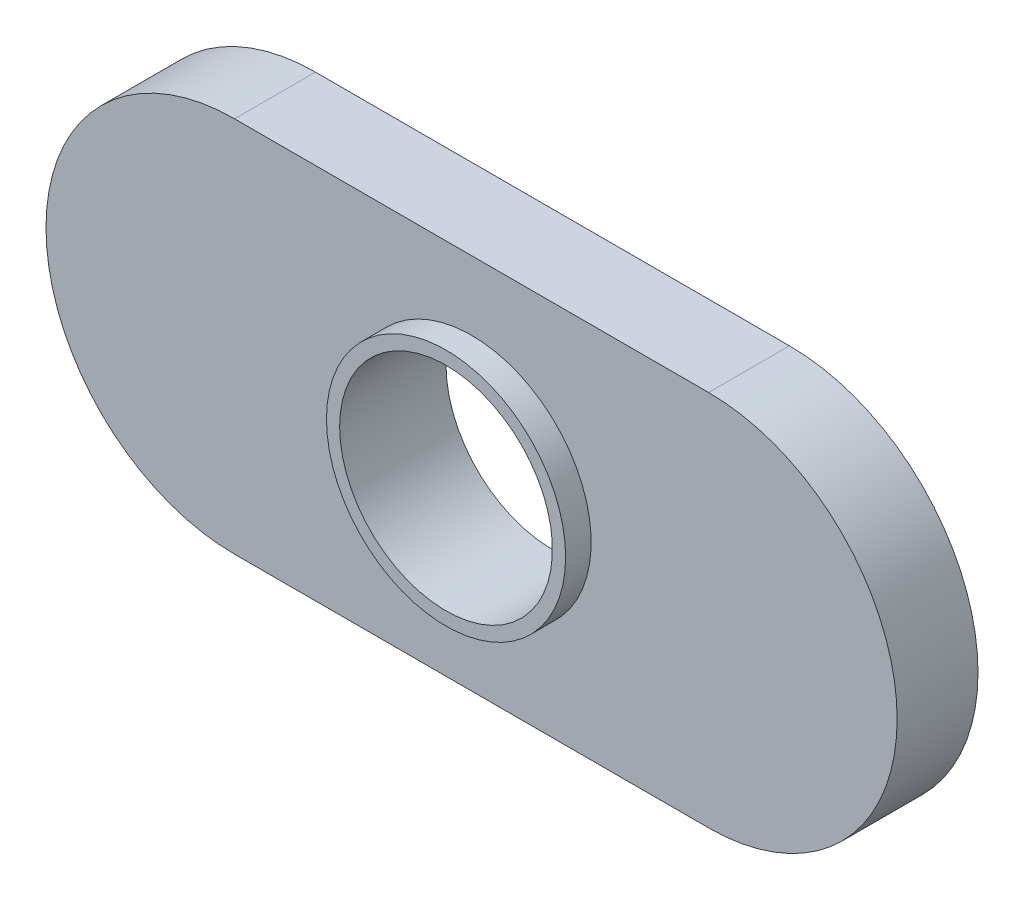
from build123d import *

# Parameters (mm, degrees)
EXTRUDE1_DEPTH     = 2.413
SKETCH4_R          = 3.5687
EXTRUDE3_DEPTH     = 0.762
SKETCH6_R          = 3.175
CUT_EXTRUDE1_DEPTH = 4.175


with BuildPart() as part:
    # Sketch1 → Extrude1 (new body)
    with BuildSketch(Plane.XY):
        with BuildLine():
            Line((111.27866266, 131.559165896), (125.42646266, 131.559165896))
            ThreePointArc((125.42646266, 131.559165896), (131.05256266, 125.933065896), (125.42646266, 120.306965896))
            Line((125.42646266, 120.306965896), (111.27866266, 120.306965896))
            ThreePointArc((111.27866266, 120.306965896), (105.65256266, 125.933065896), (111.27866266, 131.559165896))
        make_face()
    extrude(amount=EXTRUDE1_DEPTH)

    # Sketch4 → Extrude3 (add)
    with BuildSketch(Plane.XY.offset(2.413)):
        with Locations((118.35256266, 125.933065896)):
            Circle(SKETCH4_R)
    extrude(amount=EXTRUDE3_DEPTH)

    # Sketch6 → Cut-Extrude1 (cut, through all)
    with BuildSketch(Plane(origin=(0, 0, 0), x_dir=(-1, 0, 0), z_dir=(0, 0, -1))):
        with Locations((-118.35256266, 125.933065896)):
            Circle(SKETCH6_R)
    extrude(amount=-CUT_EXTRUDE1_DEPTH, mode=Mode.SUBTRACT)


solid = part.part
